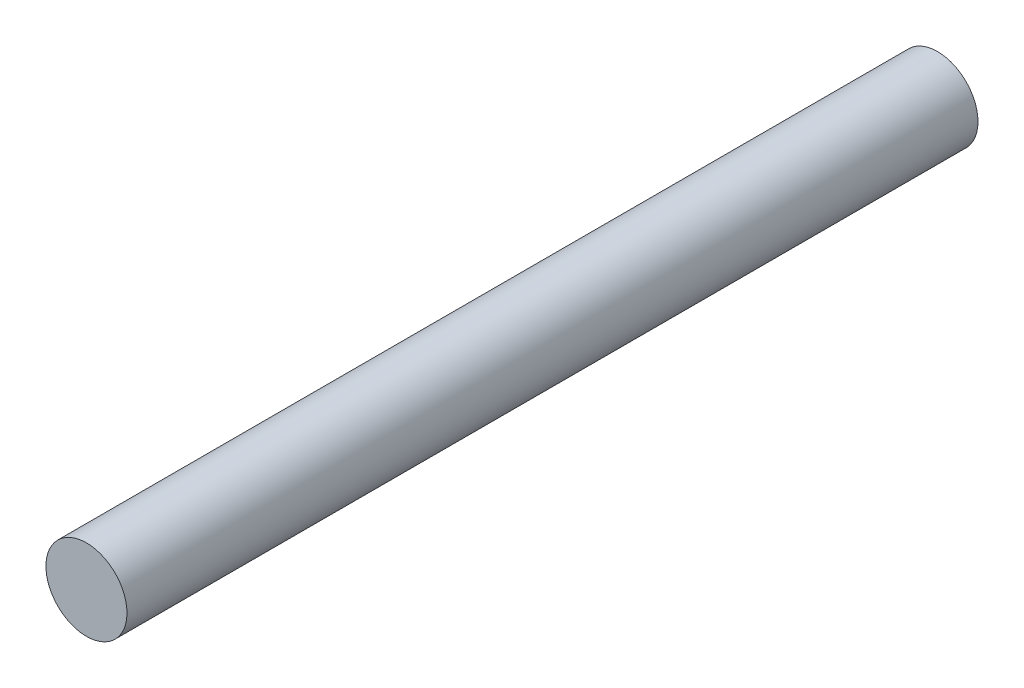
from build123d import *

# Parameters (mm, degrees)
SKETCH_1_R      = 20
EXTRUDE_2_DEPTH = 420


with BuildPart() as part:
    # 草图1 → 凸台-拉伸2 (new body)
    with BuildSketch(Plane.XY):
        Circle(SKETCH_1_R)
    extrude(amount=EXTRUDE_2_DEPTH)


solid = part.part
